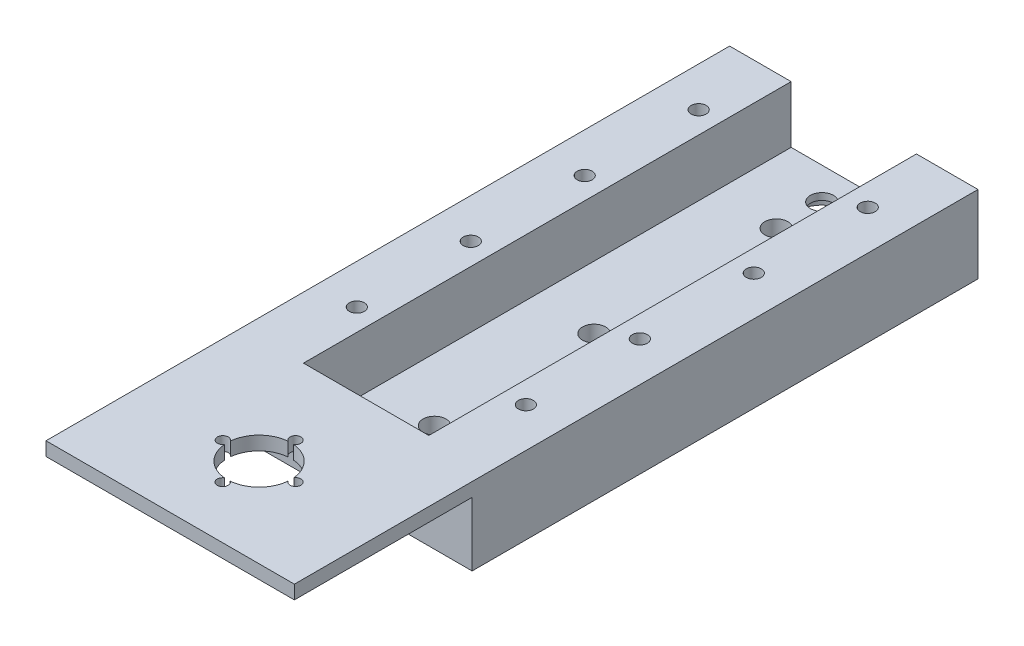
from build123d import *

# Parameters (mm, degrees)
SKETCH1_W                  = 54.5
SKETCH1_H                  = 111
BOSS_EXTRUDE1_DEPTH        = 4.5
SKETCH2_W                  = 13.5
SKETCH2_H                  = 111
BOSS_EXTRUDE2_DEPTH        = 12.5
M4X0_7_TAPPED_HOLE1_D      = 3.3
SKETCH6_W                  = 4
SKETCH6_H                  = 12.5
BOSS_EXTRUDE3_DEPTH        = 37
SKETCH7_W                  = 54.5
SKETCH7_H                  = 3
BOSS_EXTRUDE5_DEPTH        = 39
SKETCH8_R                  = 7
CUT_EXTRUDE1_DEPTH         = 3
M2_CLEARANCE_HOLE1_D       = 2.4
F_8_0_199_DIAMETER_HOLE1_D = 5.0546
SKETCH12_R                 = 5.5
CUT_EXTRUDE3_DEPTH         = 3


with BuildPart() as part:
    # Sketch1 → Boss-Extrude1 (new body)
    with BuildSketch(Plane(origin=(0, 0, 0), x_dir=(1, 0, 0), z_dir=(0, 1, 0))):
        with Locations((-13.399543841, 44.129312584)):
            Rectangle(SKETCH1_W, SKETCH1_H)
    extrude(amount=BOSS_EXTRUDE1_DEPTH)

    # Sketch2 → Boss-Extrude2 (add)
    with BuildSketch(Plane(origin=(0, 4.5, 0), x_dir=(1, 0, 0), z_dir=(0, 1, 0))):
        with Locations((7.100456159, 44.129312584)):
            Rectangle(SKETCH2_W, SKETCH2_H)
        with Locations((-33.899543841, 44.129312584)):
            Rectangle(SKETCH2_W, SKETCH2_H)
    extrude(amount=BOSS_EXTRUDE2_DEPTH)

    # M4x0.7 Tapped Hole1 (through all)
    with Locations(Plane(origin=(-31.949543841, 17, -9.129312584), x_dir=(0, 0, 1), z_dir=(0, 1, 0))):
        with Locations((0, 0), (-25, 0), (-50, 0), (-75, 0), (0, 37.1), (-25, 37.1), (-50, 37.1), (-75, 37.1)):
            Hole(M4X0_7_TAPPED_HOLE1_D / 2)

    # Sketch6 → Boss-Extrude3 (add)
    with BuildSketch(Plane(origin=(-27.149543841, 0, 0), x_dir=(0, 0, -1), z_dir=(1, 0, 0))):
        with Locations((-9.370687416, 10.75)):
            Rectangle(SKETCH6_W, SKETCH6_H)
    extrude(amount=BOSS_EXTRUDE3_DEPTH)

    # Sketch7 → Boss-Extrude5 (add)
    with BuildSketch(Plane.XY.offset(11.370687416)):
        with Locations((-13.399543841, 15.5)):
            Rectangle(SKETCH7_W, SKETCH7_H)
    extrude(amount=BOSS_EXTRUDE5_DEPTH)

    # Sketch8 → Cut-Extrude1 (cut)
    with BuildSketch(Plane(origin=(0, 17, 0), x_dir=(1, 0, 0), z_dir=(0, 1, 0))):
        with Locations((-13.399543841, -30.870687416)):
            Circle(SKETCH8_R)
    extrude(amount=-CUT_EXTRUDE1_DEPTH, mode=Mode.SUBTRACT)

    # M2 Clearance Hole1 (through all)
    with Locations(Plane(origin=(-21.371437118, 17, 30.847906254), x_dir=(0, 0, 1), z_dir=(0, 1, 0))):
        with Locations((0, 0), (-7.977218838, 7.971893277), (8.022781162, 7.971893277), (-0.002806072, 15.940961576)):
            Hole(M2_CLEARANCE_HOLE1_D / 2)

    # #8 (0.199) Diameter Hole1 (through all)
    with Locations(Plane(origin=(-13.399543841, 4.5, 2.370687416), x_dir=(0, 0, 1), z_dir=(0, 1, 0))):
        with Locations((0, 0), (-10, 0), (-45, 0), (-85, 0), (-95, 0)):
            Hole(F_8_0_199_DIAMETER_HOLE1_D / 2)

    # Sketch12 → Cut-Extrude3 (cut)
    with BuildSketch(Plane(origin=(0, 0, 0), x_dir=(-1, 0, 0), z_dir=(0, -1, 0))):
        with Locations((13.399543841, 92.629312584)):
            Circle(SKETCH12_R)
    extrude(amount=-CUT_EXTRUDE3_DEPTH, mode=Mode.SUBTRACT)


solid = part.part
